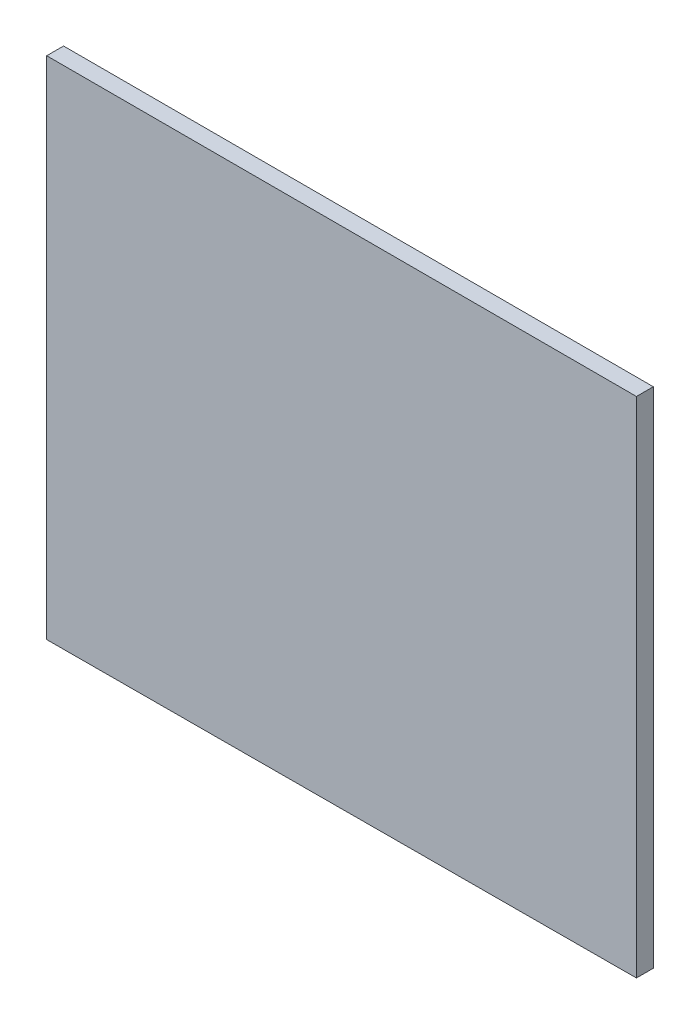
from build123d import *

# Parameters (mm, degrees)
SALIENTE_EXTRUIR1_DEPTH = 0.1


with BuildPart() as part:
    # Model → Saliente-Extruir1 (new body)
    with BuildSketch(Plane.XY):
        Polygon((42.399733425, 28.735740874), (38.900990882, 28.724982991), (38.900990882, 31.724982991), (42.399733425, 31.723700762), align=None)
    extrude(amount=SALIENTE_EXTRUIR1_DEPTH)


solid = part.part
